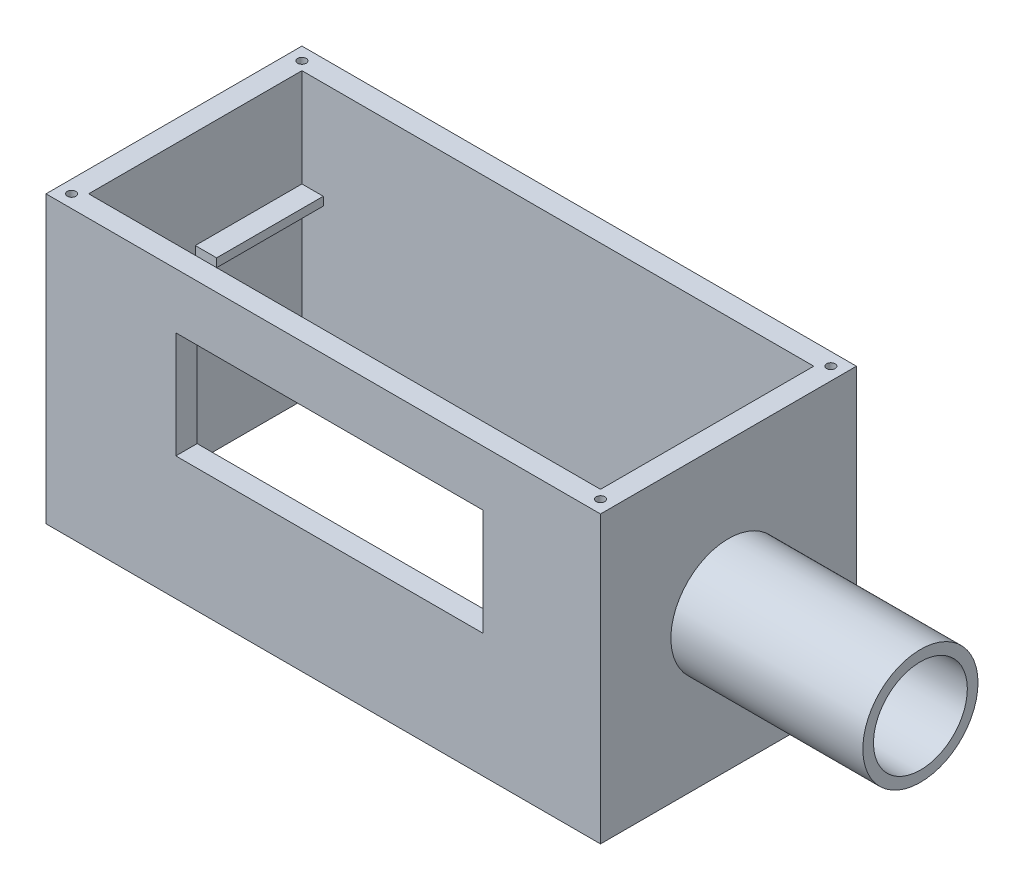
from build123d import *

# Parameters (mm, degrees)
SKETCH1_W           = 130
SKETCH1_H           = 60
BOSS_EXTRUDE1_DEPTH = 67
CUT_EXTRUDE1_REACH  = 69
SKETCH2_W           = 120
SKETCH2_H           = 50
SKETCH4_W           = 27.738428507
SKETCH4_H           = 2
BOSS_EXTRUDE2_DEPTH = 5
SKETCH5_W           = 27.5
SKETCH5_H           = 2
BOSS_EXTRUDE3_DEPTH = 5
CUT_EXTRUDE2_REACH  = 62
SKETCH6_W           = 72
SKETCH6_H           = 25
CUT_EXTRUDE3_REACH  = 69
SKETCH8_R           = 1
SKETCH9_R           = 13.5
BOSS_EXTRUDE4_DEPTH = 45
SKETCH10_R          = 11
CUT_EXTRUDE4_DEPTH  = 45


with BuildPart() as part:
    # Sketch1 → Boss-Extrude1 (new body)
    with BuildSketch(Plane(origin=(0, 0, 0), x_dir=(1, 0, 0), z_dir=(0, 1, 0))):
        Rectangle(SKETCH1_W, SKETCH1_H)
    extrude(amount=BOSS_EXTRUDE1_DEPTH)

    # Sketch2 → Cut-Extrude1 (cut, up to next)
    with BuildSketch(Plane(origin=(0, 67, 0), x_dir=(1, 0, 0), z_dir=(0, 1, 0)), mode=Mode.PRIVATE) as cut_extrude1_sk1:
        Rectangle(SKETCH2_W, SKETCH2_H)
    cut_extrude1_tool1 = extrude(cut_extrude1_sk1.sketch, amount=-CUT_EXTRUDE1_REACH, mode=Mode.PRIVATE) & part.part
    add(cut_extrude1_tool1.solids().sort_by_distance((0, 67, 0))[0], mode=Mode.SUBTRACT)

    # Sketch4 → Boss-Extrude2 (add)
    with BuildSketch(Plane.ZY.offset(-60)):
        with Locations((-13.630785747, 43)):
            Rectangle(SKETCH4_W, SKETCH4_H)
    extrude(amount=BOSS_EXTRUDE2_DEPTH)

    # Sketch5 → Boss-Extrude3 (add)
    with BuildSketch(Plane(origin=(-60, 0, 0), x_dir=(0, 0, -1), z_dir=(1, 0, 0))):
        with Locations((13.75, 43)):
            Rectangle(SKETCH5_W, SKETCH5_H)
    extrude(amount=BOSS_EXTRUDE3_DEPTH)

    # Sketch6 → Cut-Extrude2 (cut, up to next)
    with BuildSketch(Plane.XY.offset(30), mode=Mode.PRIVATE) as cut_extrude2_sk1:
        with Locations((1.435854944, 41.5)):
            Rectangle(SKETCH6_W, SKETCH6_H)
    cut_extrude2_tool1 = extrude(cut_extrude2_sk1.sketch, amount=-CUT_EXTRUDE2_REACH, mode=Mode.PRIVATE) & part.part
    add(cut_extrude2_tool1.solids().sort_by_distance((1.435855, 41.5, 30))[0], mode=Mode.SUBTRACT)

    # Sketch8 → Cut-Extrude3 (cut, up to next)
    with BuildSketch(Plane(origin=(0, 67, 0), x_dir=(1, 0, 0), z_dir=(0, 1, 0)), mode=Mode.PRIVATE) as cut_extrude3_sk1:
        with Locations((-62, 27)):
            Circle(SKETCH8_R)
    cut_extrude3_tool1 = extrude(cut_extrude3_sk1.sketch, amount=-CUT_EXTRUDE3_REACH, mode=Mode.PRIVATE) & part.part
    add(cut_extrude3_tool1.solids().sort_by_distance((-62, 67, -27))[0], mode=Mode.SUBTRACT)
    # Sketch8 → Cut-Extrude3 (cut, up to next)
    with BuildSketch(Plane(origin=(0, 67, 0), x_dir=(1, 0, 0), z_dir=(0, 1, 0)), mode=Mode.PRIVATE) as cut_extrude3_sk2:
        with Locations((62, 27)):
            Circle(SKETCH8_R)
    cut_extrude3_tool2 = extrude(cut_extrude3_sk2.sketch, amount=-CUT_EXTRUDE3_REACH, mode=Mode.PRIVATE) & part.part
    add(cut_extrude3_tool2.solids().sort_by_distance((62, 67, -27))[0], mode=Mode.SUBTRACT)
    # Sketch8 → Cut-Extrude3 (cut, up to next)
    with BuildSketch(Plane(origin=(0, 67, 0), x_dir=(1, 0, 0), z_dir=(0, 1, 0)), mode=Mode.PRIVATE) as cut_extrude3_sk3:
        with Locations((-62, -27)):
            Circle(SKETCH8_R)
    cut_extrude3_tool3 = extrude(cut_extrude3_sk3.sketch, amount=-CUT_EXTRUDE3_REACH, mode=Mode.PRIVATE) & part.part
    add(cut_extrude3_tool3.solids().sort_by_distance((-62, 67, 27))[0], mode=Mode.SUBTRACT)
    # Sketch8 → Cut-Extrude3 (cut, up to next)
    with BuildSketch(Plane(origin=(0, 67, 0), x_dir=(1, 0, 0), z_dir=(0, 1, 0)), mode=Mode.PRIVATE) as cut_extrude3_sk4:
        with Locations((62, -27)):
            Circle(SKETCH8_R)
    cut_extrude3_tool4 = extrude(cut_extrude3_sk4.sketch, amount=-CUT_EXTRUDE3_REACH, mode=Mode.PRIVATE) & part.part
    add(cut_extrude3_tool4.solids().sort_by_distance((62, 67, 27))[0], mode=Mode.SUBTRACT)

    # Sketch9 → Boss-Extrude4 (add)
    with BuildSketch(Plane(origin=(65, 0, 0), x_dir=(0, 0, -1), z_dir=(1, 0, 0))):
        with Locations((0, 33.5)):
            Circle(SKETCH9_R)
    extrude(amount=BOSS_EXTRUDE4_DEPTH)

    # Sketch10 → Cut-Extrude4 (cut)
    with BuildSketch(Plane(origin=(110, 0, 0), x_dir=(0, 0, -1), z_dir=(1, 0, 0))):
        with Locations((0, 33.5)):
            Circle(SKETCH10_R)
    extrude(amount=-CUT_EXTRUDE4_DEPTH, mode=Mode.SUBTRACT)


solid = part.part
